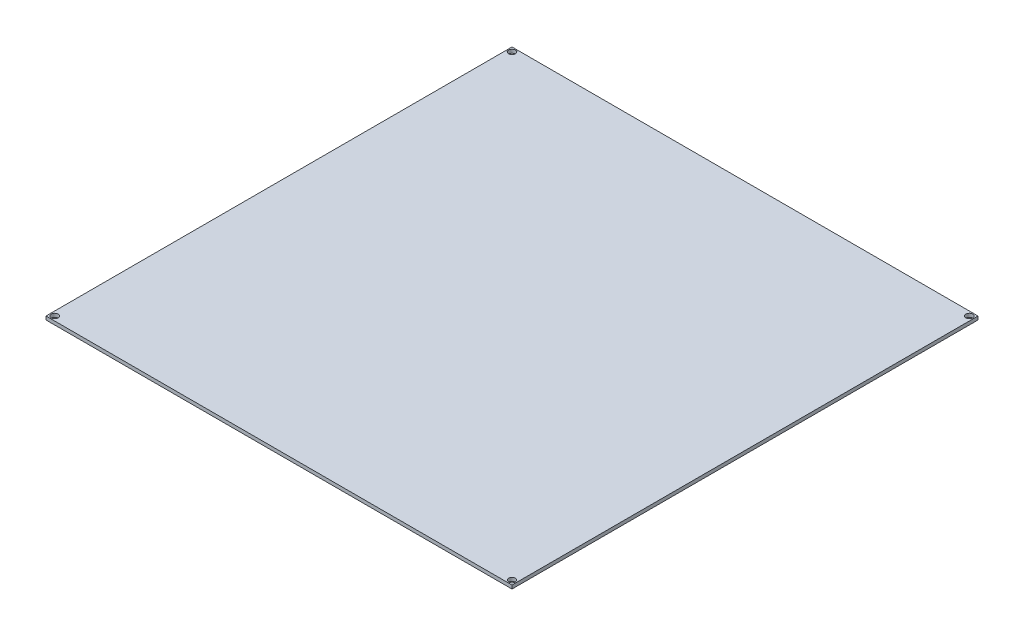
from build123d import *

# Parameters (mm, degrees)
SKETCH1_W                  = 214
SKETCH1_H                  = 214
BOSS_EXTRUDE1_DEPTH        = 1.6
M2_5_CLEARANCE_HOLE1_D     = 3.1
M2_5_CLEARANCE_HOLE1_DEPTH = 11.938
M2_5_CLEARANCE_HOLE1_TIP   = 0.931333959


with BuildPart() as part:
    # Sketch1 → Boss-Extrude1 (new body)
    with BuildSketch(Plane(origin=(0, 0, 0), x_dir=(1, 0, 0), z_dir=(0, 1, 0))):
        Rectangle(SKETCH1_W, SKETCH1_H)
    extrude(amount=BOSS_EXTRUDE1_DEPTH)

    # M2.5 Clearance Hole1
    with Locations(Plane(origin=(0, 1.6, 0), x_dir=(1, 0, 0), z_dir=(0, 1, 0))):
        with Locations((-105, 105), (105, 105), (105, -105), (-105, -105)):
            Hole(M2_5_CLEARANCE_HOLE1_D / 2, depth=M2_5_CLEARANCE_HOLE1_DEPTH)
            with Locations((0, 0, -(M2_5_CLEARANCE_HOLE1_DEPTH + M2_5_CLEARANCE_HOLE1_TIP / 2))):  # 118° drill point
                Cone(0, M2_5_CLEARANCE_HOLE1_D / 2, M2_5_CLEARANCE_HOLE1_TIP, mode=Mode.SUBTRACT)


solid = part.part
